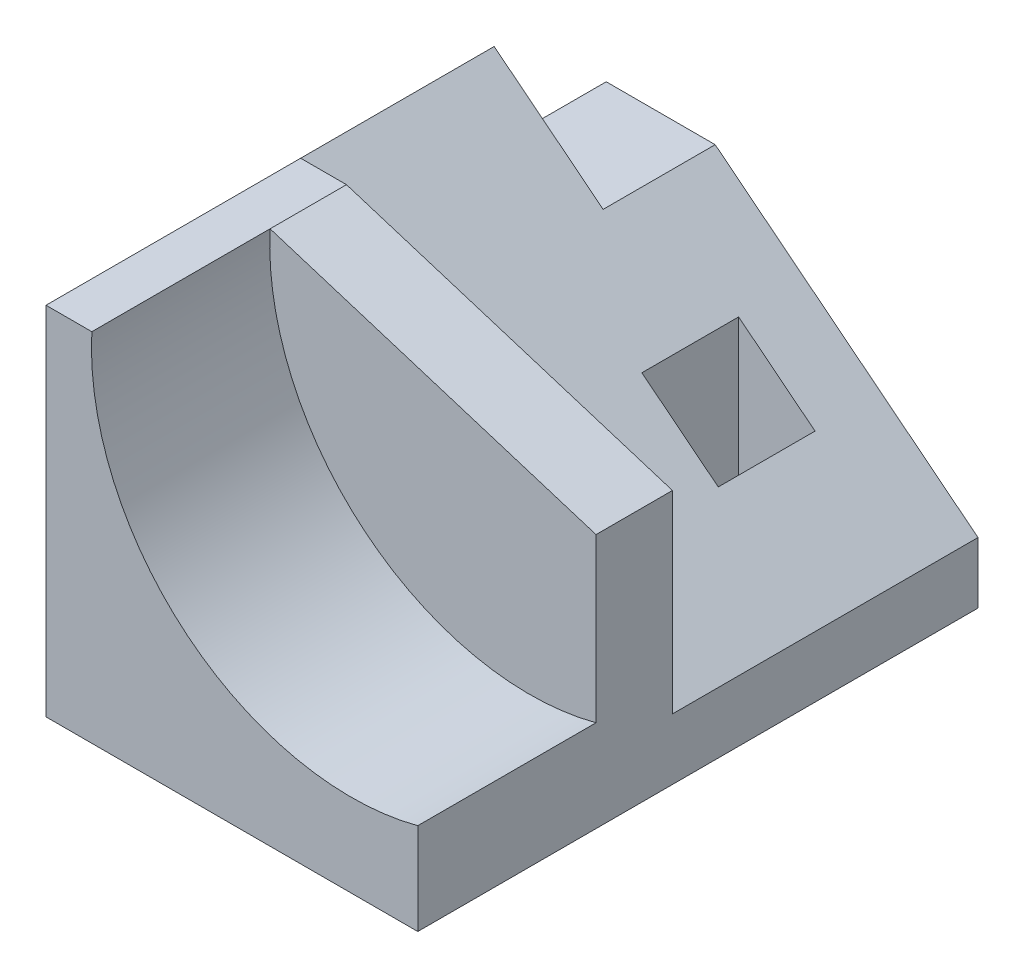
from build123d import *

# Parameters (mm, degrees)
SKETCH1_W           = 36.5
SKETCH1_H           = 55
SKETCH1_W_2         = 7.5
SKETCH1_H_2         = 9.5
BOSS_EXTRUDE1_DEPTH = 35
SKETCH3_W           = 11
SKETCH3_H           = 11
CUT_EXTRUDE2_DEPTH  = 8.5
CUT_EXTRUDE1_DEPTH  = 30
CUT_EXTRUDE3_DEPTH  = 17.5
CUT_EXTRUDE4_REACH  = 39.5


with BuildPart() as part:
    # Sketch1 → Boss-Extrude1 (new body)
    with BuildSketch(Plane(origin=(0, 0, 0), x_dir=(1, 0, 0), z_dir=(0, 1, 0))):
        Rectangle(SKETCH1_W, SKETCH1_H)
        with Locations((5, 16.25)):
            Rectangle(SKETCH1_W_2, SKETCH1_H_2, mode=Mode.SUBTRACT)
    extrude(amount=BOSS_EXTRUDE1_DEPTH)

    # Sketch3 → Cut-Extrude2 (cut)
    with BuildSketch(Plane(origin=(0, 35, 0), x_dir=(1, 0, 0), z_dir=(0, 1, 0))):
        with Locations((-12.75, 22)):
            Rectangle(SKETCH3_W, SKETCH3_H)
    extrude(amount=-CUT_EXTRUDE2_DEPTH, mode=Mode.SUBTRACT)

    # Sketch2 → Cut-Extrude1 (cut)
    with BuildSketch(Plane(origin=(0, 0, -27.5), x_dir=(-1, 0, 0), z_dir=(0, 0, -1))):
        Polygon((7.551724138, 26.5), (18.25, 35), (7.25, 35), (7.25, 26.5), align=None)
        Polygon((-18.25, 6), (7.551724138, 26.5), (7.25, 26.5), (7.25, 35), (-18.25, 35), align=None)
    extrude(amount=-CUT_EXTRUDE1_DEPTH, mode=Mode.SUBTRACT)

    # Sketch4 → Cut-Extrude3 (cut)
    with BuildSketch(Plane.XY.offset(27.5)):
        with BuildLine():
            ThreePointArc((-13.75, 35), (-4.365969084, 13.85726882), (18.25, 9))
            Line((18.25, 9), (18.25, 35))
            Line((18.25, 35), (-13.75, 35))
        make_face()
    extrude(amount=-CUT_EXTRUDE3_DEPTH, mode=Mode.SUBTRACT)

    # Sketch5 → Cut-Extrude4 (cut, up to next)
    with BuildSketch(Plane.XY.offset(10), mode=Mode.PRIVATE) as cut_extrude4_sk1:
        Polygon((18.25, 35), (-13.75, 35), (18.25, 25), align=None)
    cut_extrude4_tool1 = extrude(cut_extrude4_sk1.sketch, amount=-CUT_EXTRUDE4_REACH, mode=Mode.PRIVATE) & part.part
    add(cut_extrude4_tool1.solids().sort_by_distance((7.583333, 31.666667, 10))[0], mode=Mode.SUBTRACT)


solid = part.part
